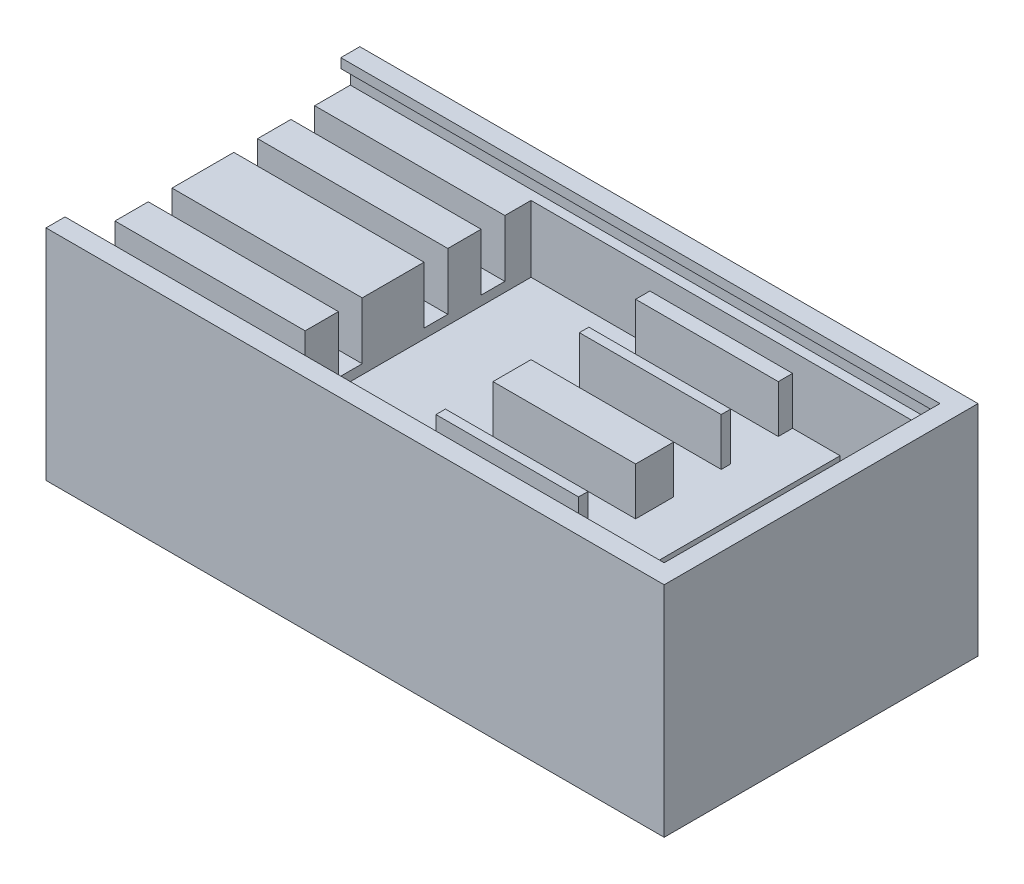
from build123d import *

# Parameters (mm, degrees)
SKETCH1_W            = 65
SKETCH1_H            = 33
BOSS_EXTRUDE1_DEPTH  = 2
SKETCH2_W            = 65
SKETCH2_H            = 33
SKETCH2_W_2          = 61
SKETCH2_H_2          = 29
BOSS_EXTRUDE2_DEPTH  = 21
SKETCH3_W            = 50.5
SKETCH3_H            = 29
BOSS_EXTRUDE3_DEPTH  = 11
SKETCH4_R            = 3
CUT_EXTRUDE1_DEPTH   = 2
SKETCH5_W            = 4
SKETCH5_H            = 6
BOSS_EXTRUDE4_DEPTH  = 9.5
SKETCH6_W            = 4
SKETCH6_H            = 6
BOSS_EXTRUDE5_DEPTH  = 9.5
SKETCH7_W            = 3
SKETCH7_H            = 4
BOSS_EXTRUDE8_DEPTH  = 9.5
SKETCH9_W            = 3
SKETCH9_H            = 4
BOSS_EXTRUDE9_DEPTH  = 9.5
SKETCH10_W           = 3
SKETCH10_H           = 4
BOSS_EXTRUDE10_DEPTH = 9.5
SKETCH11_W           = 2
SKETCH11_H           = 29
CUT_EXTRUDE2_DEPTH   = 3
SKETCH13_W           = 31
SKETCH13_H           = 2
CUT_EXTRUDE3_DEPTH   = 63
SKETCH14_W           = 15
SKETCH14_H           = 1.5
BOSS_EXTRUDE11_DEPTH = 5
SKETCH15_W           = 15
SKETCH15_H           = 1.5
BOSS_EXTRUDE12_DEPTH = 5
SKETCH16_W           = 14.920438195
SKETCH16_H           = 1
BOSS_EXTRUDE13_DEPTH = 5
SKETCH17_W           = 15
SKETCH17_H           = 1
BOSS_EXTRUDE14_DEPTH = 5
SKETCH18_W           = 15
SKETCH18_H           = 4
BOSS_EXTRUDE15_DEPTH = 5
SKETCH19_W           = 18
SKETCH19_H           = 29
BOSS_EXTRUDE16_DEPTH = 7
SKETCH20_W           = 20
SKETCH20_H           = 2.5
CUT_EXTRUDE4_DEPTH   = 6
SKETCH21_W           = 20
SKETCH21_H           = 2.5
CUT_EXTRUDE5_DEPTH   = 6
SKETCH22_W           = 20
SKETCH22_H           = 2.5
CUT_EXTRUDE6_DEPTH   = 6
SKETCH23_W           = 20
SKETCH23_H           = 2.5
CUT_EXTRUDE7_DEPTH   = 6


with BuildPart() as part:
    # Sketch1 → Boss-Extrude1 (new body)
    with BuildSketch(Plane(origin=(0, 0, 0), x_dir=(1, 0, 0), z_dir=(0, 1, 0))):
        Rectangle(SKETCH1_W, SKETCH1_H)
    extrude(amount=BOSS_EXTRUDE1_DEPTH)

    # Sketch2 → Boss-Extrude2 (add)
    with BuildSketch(Plane(origin=(0, 2, 0), x_dir=(1, 0, 0), z_dir=(0, 1, 0))):
        Rectangle(SKETCH2_W, SKETCH2_H)
        Rectangle(SKETCH2_W_2, SKETCH2_H_2, mode=Mode.SUBTRACT)
    extrude(amount=BOSS_EXTRUDE2_DEPTH)

    # Sketch3 → Boss-Extrude3 (add)
    with BuildSketch(Plane(origin=(0, 2, 0), x_dir=(1, 0, 0), z_dir=(0, 1, 0))):
        with Locations((-5.25, 0)):
            Rectangle(SKETCH3_W, SKETCH3_H)
    extrude(amount=BOSS_EXTRUDE3_DEPTH)

    # Sketch4 → Cut-Extrude1 (cut)
    with BuildSketch(Plane(origin=(0, 2, 0), x_dir=(1, 0, 0), z_dir=(0, 1, 0))):
        with Locations((26.5, 0)):
            Circle(SKETCH4_R)
    extrude(amount=-CUT_EXTRUDE1_DEPTH, mode=Mode.SUBTRACT)

    # Sketch5 → Boss-Extrude4 (add)
    with BuildSketch(Plane(origin=(0, 2, 0), x_dir=(1, 0, 0), z_dir=(0, 1, 0))):
        with Locations((22, 11.5)):
            Rectangle(SKETCH5_W, SKETCH5_H)
    extrude(amount=BOSS_EXTRUDE4_DEPTH)

    # Sketch6 → Boss-Extrude5 (add)
    with BuildSketch(Plane(origin=(0, 2, 0), x_dir=(1, 0, 0), z_dir=(0, 1, 0))):
        with Locations((22, -11.5)):
            Rectangle(SKETCH6_W, SKETCH6_H)
    extrude(amount=BOSS_EXTRUDE5_DEPTH)

    # Sketch7 → Boss-Extrude8 (add)
    with BuildSketch(Plane(origin=(0, 2, 0), x_dir=(1, 0, 0), z_dir=(0, 1, 0))):
        with Locations((29, 6)):
            Rectangle(SKETCH7_W, SKETCH7_H)
    extrude(amount=BOSS_EXTRUDE8_DEPTH)

    # Sketch9 → Boss-Extrude9 (add)
    with BuildSketch(Plane(origin=(0, 2, 0), x_dir=(1, 0, 0), z_dir=(0, 1, 0))):
        with Locations((29, -6)):
            Rectangle(SKETCH9_W, SKETCH9_H)
    extrude(amount=BOSS_EXTRUDE9_DEPTH)

    # Sketch10 → Boss-Extrude10 (add)
    with BuildSketch(Plane(origin=(0, 2, 0), x_dir=(1, 0, 0), z_dir=(0, 1, 0))):
        with Locations((21.5, 0)):
            Rectangle(SKETCH10_W, SKETCH10_H)
    extrude(amount=BOSS_EXTRUDE10_DEPTH)

    # Sketch11 → Cut-Extrude2 (cut)
    with BuildSketch(Plane(origin=(0, 23, 0), x_dir=(1, 0, 0), z_dir=(0, 1, 0))):
        with Locations((-31.5, 0)):
            Rectangle(SKETCH11_W, SKETCH11_H)
    extrude(amount=-CUT_EXTRUDE2_DEPTH, mode=Mode.SUBTRACT)

    # Sketch13 → Cut-Extrude3 (cut)
    with BuildSketch(Plane.ZY.offset(32.5)):
        with Locations((0, 21)):
            Rectangle(SKETCH13_W, SKETCH13_H)
    extrude(amount=-CUT_EXTRUDE3_DEPTH, mode=Mode.SUBTRACT)

    # Sketch14 → Boss-Extrude11 (add)
    with BuildSketch(Plane(origin=(0, 13, 0), x_dir=(1, 0, 0), z_dir=(0, 1, 0))):
        with Locations((7.5, 13.75)):
            Rectangle(SKETCH14_W, SKETCH14_H)
    extrude(amount=BOSS_EXTRUDE11_DEPTH)

    # Sketch15 → Boss-Extrude12 (add)
    with BuildSketch(Plane(origin=(0, 13, 0), x_dir=(1, 0, 0), z_dir=(0, 1, 0))):
        with Locations((7.5, -13.75)):
            Rectangle(SKETCH15_W, SKETCH15_H)
    extrude(amount=BOSS_EXTRUDE12_DEPTH)

    # Sketch16 → Boss-Extrude13 (add)
    with BuildSketch(Plane(origin=(0, 13, 0), x_dir=(1, 0, 0), z_dir=(0, 1, 0))):
        with Locations((7.539780903, 7.5)):
            Rectangle(SKETCH16_W, SKETCH16_H)
    extrude(amount=BOSS_EXTRUDE13_DEPTH)

    # Sketch17 → Boss-Extrude14 (add)
    with BuildSketch(Plane(origin=(0, 13, 0), x_dir=(1, 0, 0), z_dir=(0, 1, 0))):
        with Locations((7.5, -7.5)):
            Rectangle(SKETCH17_W, SKETCH17_H)
    extrude(amount=BOSS_EXTRUDE14_DEPTH)

    # Sketch18 → Boss-Extrude15 (add)
    with BuildSketch(Plane(origin=(0, 13, 0), x_dir=(1, 0, 0), z_dir=(0, 1, 0))):
        with Locations((7.5, 0)):
            Rectangle(SKETCH18_W, SKETCH18_H)
    extrude(amount=BOSS_EXTRUDE15_DEPTH)

    # Sketch19 → Boss-Extrude16 (add)
    with BuildSketch(Plane(origin=(0, 13, 0), x_dir=(1, 0, 0), z_dir=(0, 1, 0))):
        with Locations((-21.5, 0)):
            Rectangle(SKETCH19_W, SKETCH19_H)
    extrude(amount=BOSS_EXTRUDE16_DEPTH)

    # Sketch20 → Cut-Extrude4 (cut)
    with BuildSketch(Plane(origin=(0, 20, 0), x_dir=(1, 0, 0), z_dir=(0, 1, 0))):
        with Locations((-22.5, 10.5)):
            Rectangle(SKETCH20_W, SKETCH20_H)
    extrude(amount=-CUT_EXTRUDE4_DEPTH, mode=Mode.SUBTRACT)

    # Sketch21 → Cut-Extrude5 (cut)
    with BuildSketch(Plane(origin=(0, 20, 0), x_dir=(1, 0, 0), z_dir=(0, 1, 0))):
        with Locations((-22.5, -10.5)):
            Rectangle(SKETCH21_W, SKETCH21_H)
    extrude(amount=-CUT_EXTRUDE5_DEPTH, mode=Mode.SUBTRACT)

    # Sketch22 → Cut-Extrude6 (cut)
    with BuildSketch(Plane(origin=(0, 20, 0), x_dir=(1, 0, 0), z_dir=(0, 1, 0))):
        with Locations((-22.5, 4.5)):
            Rectangle(SKETCH22_W, SKETCH22_H)
    extrude(amount=-CUT_EXTRUDE6_DEPTH, mode=Mode.SUBTRACT)

    # Sketch23 → Cut-Extrude7 (cut)
    with BuildSketch(Plane(origin=(0, 20, 0), x_dir=(1, 0, 0), z_dir=(0, 1, 0))):
        with Locations((-22.5, -4.5)):
            Rectangle(SKETCH23_W, SKETCH23_H)
    extrude(amount=-CUT_EXTRUDE7_DEPTH, mode=Mode.SUBTRACT)


solid = part.part
